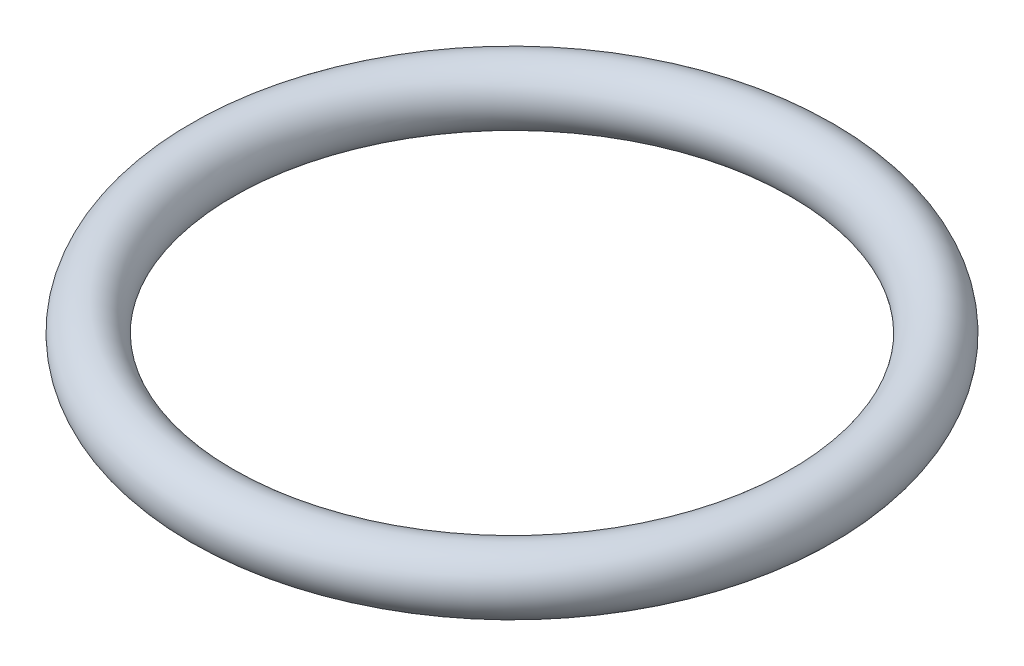
from build123d import *

# Parameters (mm, degrees)
SKETCH4_R = 0.85


with BuildPart() as part:
    # Body: sweep along a path in Sketch3
    with BuildLine(Plane(origin=(0, 0, 0), x_dir=(1, 0, 0), z_dir=(0, 1, 0))) as body_path:
        CenterArc((0, 0), 8.53907747, 0, 360)
    # Sketch4 → Body (sweep)
    with BuildSketch(Plane.XY):
        with Locations((8.53907747, 0)):
            Circle(SKETCH4_R)
    sweep(path=body_path.line)


solid = part.part
